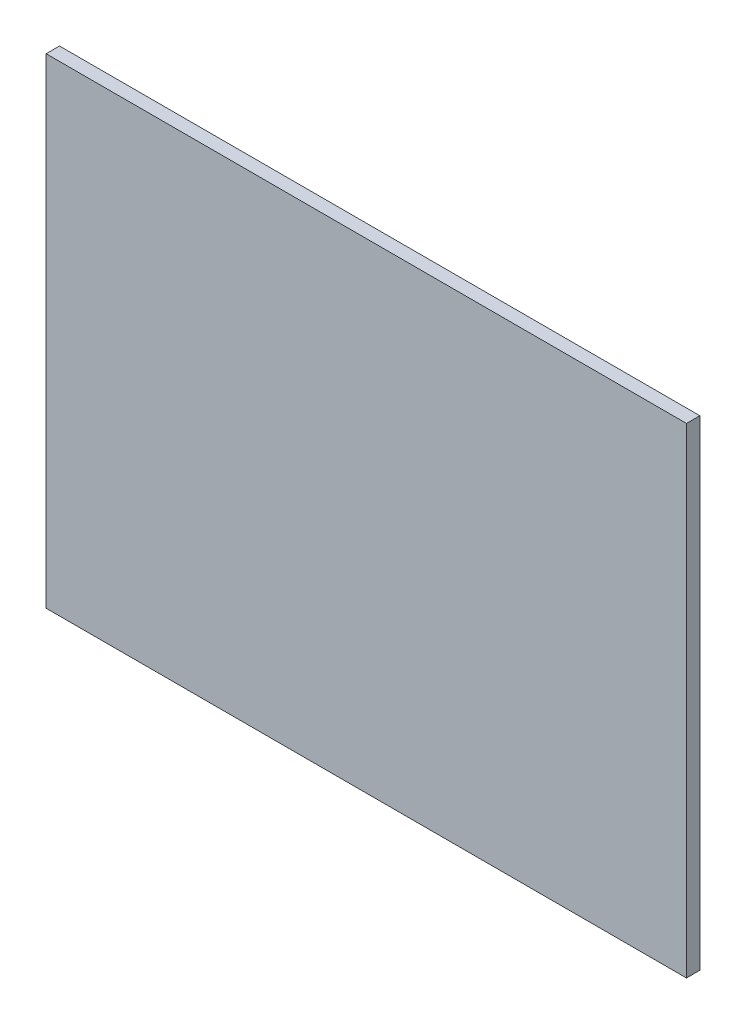
from build123d import *

# Parameters (mm, degrees)
SKETCH1_W           = 152.4
SKETCH1_H           = 114.3
BOSS_EXTRUDE1_DEPTH = 3.18


with BuildPart() as part:
    # Sketch1 → Boss-Extrude1 (new body)
    with BuildSketch(Plane.XY):
        Rectangle(SKETCH1_W, SKETCH1_H)
    extrude(amount=BOSS_EXTRUDE1_DEPTH)


solid = part.part
